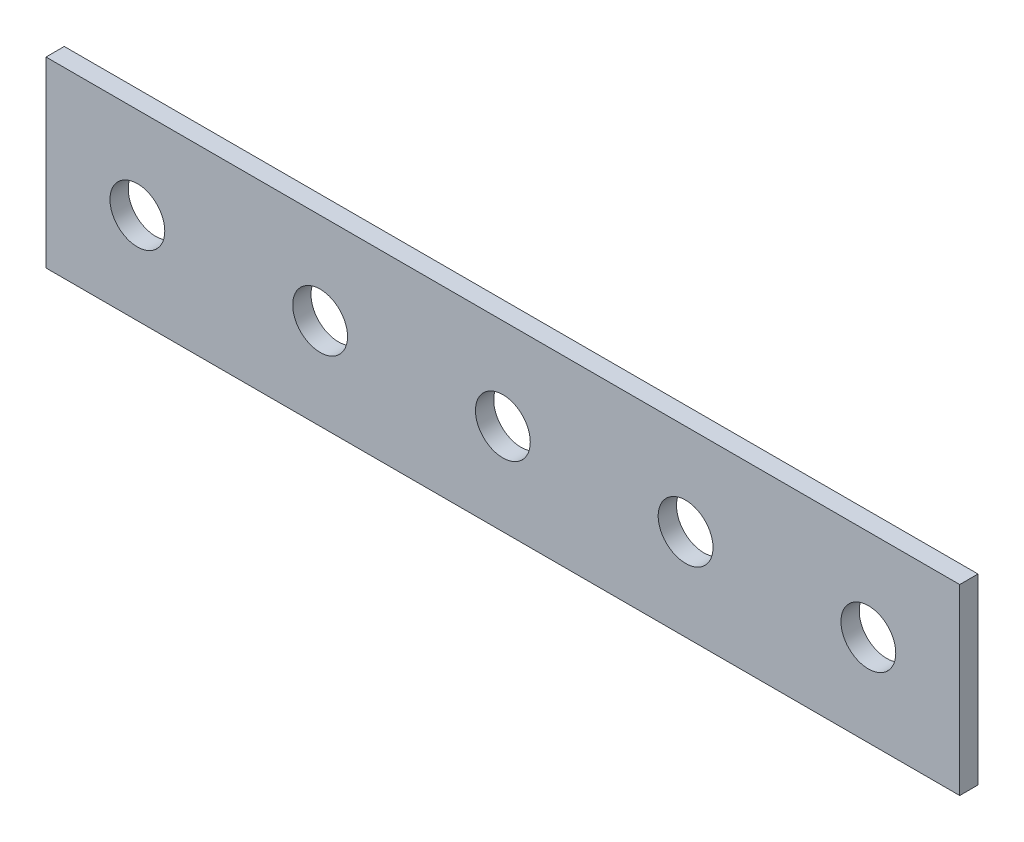
from build123d import *

# Parameters (mm, degrees)
ESQUISSE1_W           = 50
ESQUISSE1_H           = 10
MAIN_DEPTH            = 1
ESQUISSE2_R           = 1.5
HOLE_DEPTH            = 2
REPEATHOLERIGHT_COUNT = 3
REPEATHOLERIGHT_PITCH = 10
REPEATHOLELEFT_COUNT  = 3
REPEATHOLELEFT_PITCH  = 10


with BuildPart() as part:
    # Esquisse1 → Main (new body)
    with BuildSketch(Plane.XY):
        with Locations((25, 5)):
            Rectangle(ESQUISSE1_W, ESQUISSE1_H)
    extrude(amount=MAIN_DEPTH)

    # Esquisse2 → Hole (cut, through all)
    with BuildSketch(Plane.XY.offset(1)):
        with Locations((25, 5)):
            Circle(ESQUISSE2_R)
    hole = extrude(amount=-HOLE_DEPTH, mode=Mode.SUBTRACT)

    # RepeatHoleRight: Hole ×3
    with Locations(*[(i * REPEATHOLERIGHT_PITCH, 0, 0) for i in range(1, REPEATHOLERIGHT_COUNT)]):
        add(hole, mode=Mode.SUBTRACT)

    # RepeatHoleLeft: Hole ×3
    with Locations(*[(-i * REPEATHOLELEFT_PITCH, 0, 0) for i in range(1, REPEATHOLELEFT_COUNT)]):
        add(hole, mode=Mode.SUBTRACT)


solid = part.part
